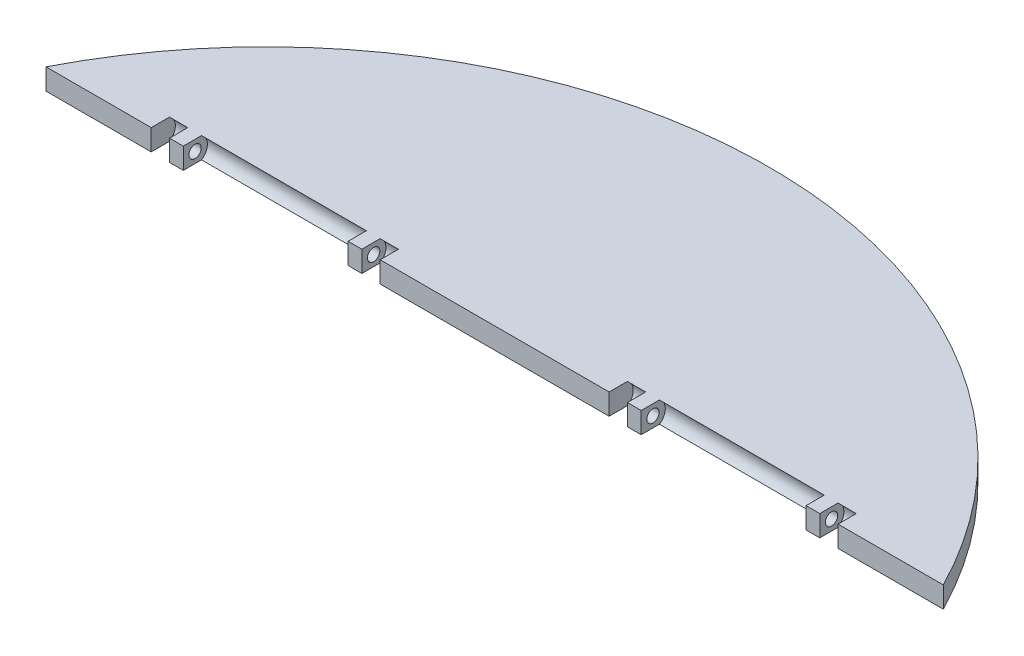
from build123d import *

# Parameters (mm, degrees)
BOSS_EXTRUDE1_DEPTH = 2.3
CUT_EXTRUDE1_START  = 25
CUT_EXTRUDE1_DEPTH  = 12.5
BOSS_EXTRUDE2_START = 35.5
SKETCH2_8_R         = 0.675
BOSS_EXTRUDE2_DEPTH = 1.5
BOSS_EXTRUDE5_START = 16
SKETCH2_11_R        = 0.675
BOSS_EXTRUDE5_DEPTH = 1.5
BOSS_EXTRUDE3_START = 10.5
SKETCH4_R           = 0.825
BOSS_EXTRUDE3_DEPTH = 1


with BuildPart() as part:
    # Sketch1 → Boss-Extrude1 (new body)
    with BuildSketch(Plane(origin=(0, 0, 0), x_dir=(1, 0, 0), z_dir=(0, 1, 0))):
        with BuildLine():
            ThreePointArc((48.989794856, 25), (0, 55), (-48.989794856, 25))
            Line((-48.989794856, 25), (48.989794856, 25))
        make_face()
    extrude(amount=BOSS_EXTRUDE1_DEPTH)

    # Sketch2 → Cut-Extrude1 (cut, symmetric)
    with BuildSketch(Plane(origin=(0, 0, 0), x_dir=(0, 0, -1), z_dir=(1, 0, 0)).offset(CUT_EXTRUDE1_START)):
        with BuildLine():
            Line((25, 2.3), (25, 0))
            Line((25, 0), (26.991919376, 0))
            ThreePointArc((26.991919376, 0), (27.634812595, 1.15), (26.991919376, 2.3))
            Line((26.991919376, 2.3), (25, 2.3))
        make_face()
    cut_extrude1 = extrude(amount=CUT_EXTRUDE1_DEPTH, both=True, mode=Mode.SUBTRACT)

    # Sketch2_8 → Boss-Extrude2 (add)
    with BuildSketch(Plane(origin=(0, 0, 0), x_dir=(0, 0, -1), z_dir=(1, 0, 0)).offset(BOSS_EXTRUDE2_START)):
        with BuildLine():
            Line((25, 2.3), (25, 0))
            Line((25, 0), (26.991919376, 0))
            ThreePointArc((26.991919376, 0), (27.634812595, 1.15), (26.991919376, 2.3))
            Line((26.991919376, 2.3), (25, 2.3))
        make_face()
        with Locations((26.284812595, 1.15)):
            Circle(SKETCH2_8_R, mode=Mode.SUBTRACT)
    boss_extrude2 = extrude(amount=-BOSS_EXTRUDE2_DEPTH)

    # Sketch2_11 → Boss-Extrude5 (add)
    with BuildSketch(Plane(origin=(0, 0, 0), x_dir=(0, 0, -1), z_dir=(1, 0, 0)).offset(BOSS_EXTRUDE5_START)):
        with BuildLine():
            Line((25, 2.3), (25, 0))
            Line((25, 0), (26.991919376, 0))
            ThreePointArc((26.991919376, 0), (27.634812595, 1.15), (26.991919376, 2.3))
            Line((26.991919376, 2.3), (25, 2.3))
        make_face()
        with Locations((26.284812595, 1.15)):
            Circle(SKETCH2_11_R, mode=Mode.SUBTRACT)
    boss_extrude5 = extrude(amount=-BOSS_EXTRUDE5_DEPTH)

    # Mirror1: Cut-Extrude1, Boss-Extrude2, Boss-Extrude5 across plane
    add(cut_extrude1.mirror(Plane(origin=(0, 0, 0), x_dir=(0, 0, 1), z_dir=(1, 0, 0))), mode=Mode.SUBTRACT)
    add(boss_extrude2.mirror(Plane(origin=(0, 0, 0), x_dir=(0, 0, 1), z_dir=(1, 0, 0))))
    add(boss_extrude5.mirror(Plane(origin=(0, 0, 0), x_dir=(0, 0, 1), z_dir=(1, 0, 0))))

    # Sketch4 → Boss-Extrude3 (add, symmetric)
    with BuildSketch(Plane(origin=(0, 0, 0), x_dir=(0, 0, -1), z_dir=(1, 0, 0)).offset(BOSS_EXTRUDE3_START)):
        with BuildLine():
            Line((41.125, 0), (38.875, 0))
            Line((38.875, 0), (38.875, -1.8))
            ThreePointArc((38.875, -1.8), (40, -2.925), (41.125, -1.8))
            Line((41.125, -1.8), (41.125, 0))
        make_face()
        with Locations((40, -1.8)):
            Circle(SKETCH4_R, mode=Mode.SUBTRACT)
    extrude(amount=BOSS_EXTRUDE3_DEPTH, both=True)


solid = part.part
